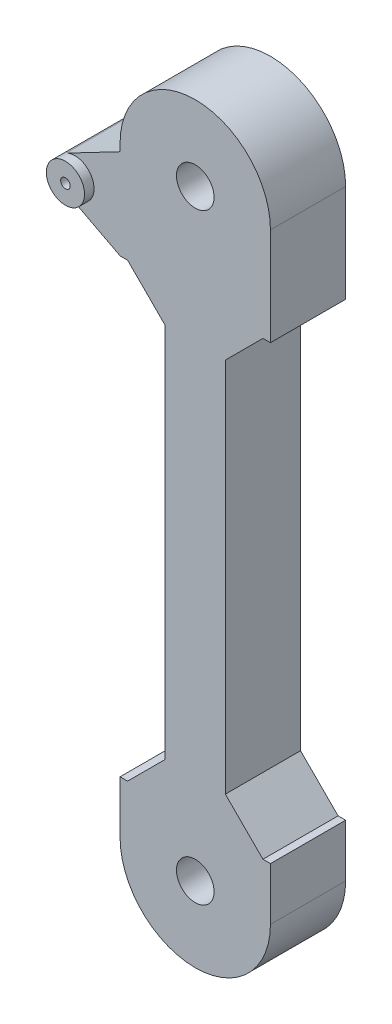
from build123d import *

# Parameters (mm, degrees)
BOSS_EXTRUDE1_DEPTH     = 10
SKETCH2_R               = 2.5
CUT_EXTRUDE1_DEPTH      = 11
BOSS_EXTRUDE2_DEPTH     = 10
SKETCH4_R               = 0.635
CUT_EXTRUDE2_DEPTH      = 11
SKETCH5_R               = 2.54
SKETCH5_R_2             = 0.635
BOSS_EXTRUDE3_DEPTH     = 1.27
SKETCH6_W               = 6
SKETCH6_H               = 60
CUT_EXTRUDE3_DEPTH      = 2.27
CUT_EXTRUDE3_DEPTH_BACK = 11
CHAMFER1_SIZE           = 5


with BuildPart() as part:
    # Sketch1 → Boss-Extrude1 (new body)
    with BuildSketch(Plane.XY):
        with BuildLine():
            Line((-10, 80), (-10, 0))
            ThreePointArc((-10, 0), (0, -10), (10, 0))
            Line((10, 0), (10, 80))
            ThreePointArc((10, 80), (0, 90), (-10, 80))
        make_face()
    extrude(amount=BOSS_EXTRUDE1_DEPTH)

    # Sketch2 → Cut-Extrude1 (cut, through all)
    with BuildSketch(Plane.XY.offset(10)):
        Circle(SKETCH2_R)
        with Locations((0, 80)):
            Circle(SKETCH2_R)
    extrude(amount=-CUT_EXTRUDE1_DEPTH, mode=Mode.SUBTRACT)

    # Sketch3 → Boss-Extrude2 (add)
    with BuildSketch(Plane.XY.offset(10)):
        with BuildLine():
            Line((-10, 79), (-17.176061622, 75.251328288))
            ThreePointArc((-17.176061622, 75.251328288), (-18.54, 73), (-17.176061622, 70.748671712))
            Line((-17.176061622, 70.748671712), (-10, 67))
            Line((-10, 67), (-10, 79))
        make_face()
    extrude(amount=-BOSS_EXTRUDE2_DEPTH)

    # Sketch4 → Cut-Extrude2 (cut, through all)
    with BuildSketch(Plane.XY.offset(10)):
        with Locations((-16, 73)):
            Circle(SKETCH4_R)
    extrude(amount=-CUT_EXTRUDE2_DEPTH, mode=Mode.SUBTRACT)

    # Sketch5 → Boss-Extrude3 (add)
    with BuildSketch(Plane.XY.offset(10)):
        with Locations((-16, 73)):
            Circle(SKETCH5_R)
        with Locations((-16, 73)):
            Circle(SKETCH5_R_2, mode=Mode.SUBTRACT)
    extrude(amount=BOSS_EXTRUDE3_DEPTH)

    # Sketch6 → Cut-Extrude3 (cut, two sides)
    with BuildSketch(Plane.XY.offset(10)) as cut_extrude3_sk:
        with Locations((-7, 37)):
            Rectangle(SKETCH6_W, SKETCH6_H)
        with Locations((7, 37)):
            Rectangle(SKETCH6_W, SKETCH6_H)
    extrude(amount=CUT_EXTRUDE3_DEPTH, mode=Mode.SUBTRACT)
    extrude(cut_extrude3_sk.sketch, amount=-CUT_EXTRUDE3_DEPTH_BACK, mode=Mode.SUBTRACT)

    # Chamfer1
    chamfer1_edges = [part.edges().sort_by_distance(p)[0] for p in [
        (-4, 67, 5),
        (-4, 7, 5),
        (4, 7, 5),
        (4, 67, 5),
    ]]
    chamfer(chamfer1_edges, length=CHAMFER1_SIZE)


solid = part.part
